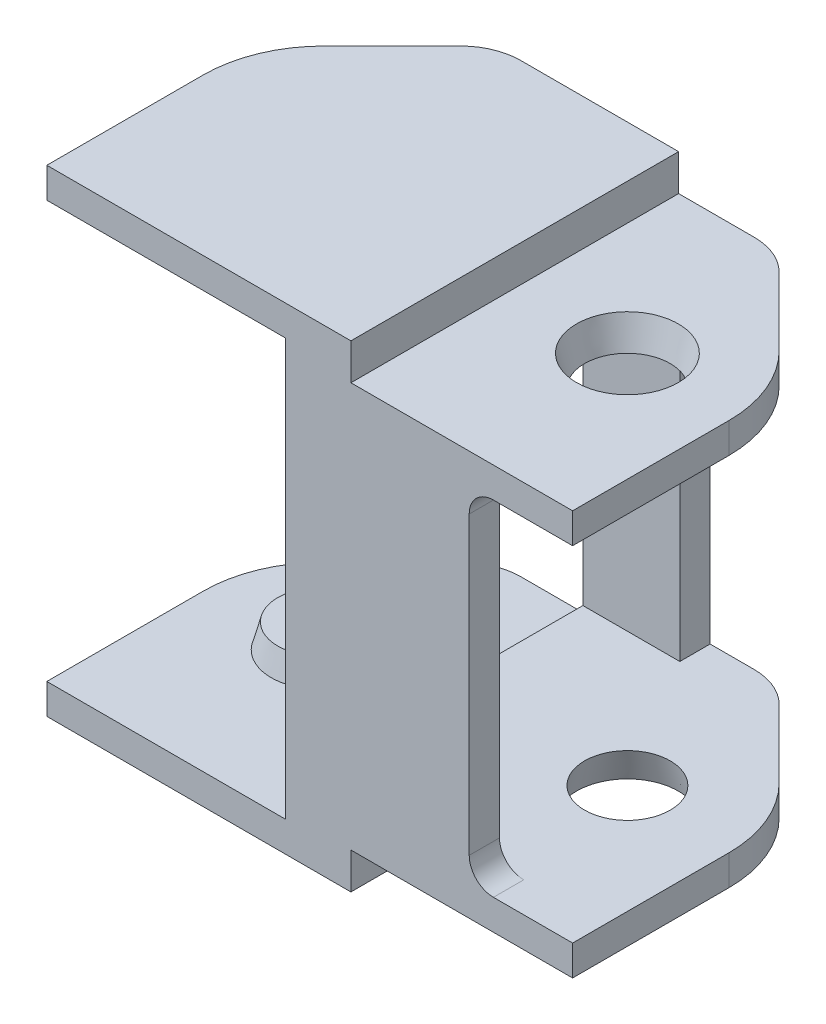
from build123d import *

# Parameters (mm, degrees)
BOSS_EXTRUDE1_DEPTH = 13.525
SKETCH3_W           = 11.025
SKETCH3_H           = 14.2
CUT_EXTRUDE1_DEPTH  = 5
SKETCH4_R           = 2
BOSS_PIVOT_DEPTH    = 1
BOSS_PIVOT_TAPER    = 15
SKETCH6_R           = 2.1
PIVOT_RECESS_DEPTH  = 1.25
PIVOT_RECESS_TAPER  = 15
CHAMFER5_SIZE       = 5
FILLET2_R           = 5
FILLET3_R           = 2.5
SKETCH8_W           = 3.997196271
SKETCH8_H           = 14.2
BOSS_EXTRUDE4_DEPTH = 1.25
FILLET4_R           = 1


with BuildPart() as part:
    # Sketch1 → Boss-Extrude1 (new body)
    with BuildSketch(Plane.XY):
        Polygon((5.35, 3.25), (5.35, 1.25), (-4.5, 1.25), (-4.5, 0), (8.05, 0), (8.05, 1.5), (17.2, 1.5), (17.2, 2.75), (9.35, 2.75), (9.35, 16.95), (17.2, 16.95), (17.2, 18.2), (8.05, 18.2), (8.05, 19.7), (-4.5, 19.7), (-4.5, 18.45), (5.35, 18.45), align=None)
    extrude(amount=BOSS_EXTRUDE1_DEPTH)

    # Sketch3 → Cut-Extrude1 (cut)
    with BuildSketch(Plane(origin=(9.35, 0, 0), x_dir=(0, 0, -1), z_dir=(1, 0, 0))):
        with Locations((-6.7625, 9.85)):
            Rectangle(SKETCH3_W, SKETCH3_H)
    extrude(amount=-CUT_EXTRUDE1_DEPTH, mode=Mode.SUBTRACT)

    # Sketch4 → boss pivot (add)
    with BuildSketch(Plane.XZ.offset(-18.45)):
        with Locations((0, 6.7625)):
            Circle(SKETCH4_R)
    boss_pivot = extrude(amount=BOSS_PIVOT_DEPTH, taper=BOSS_PIVOT_TAPER)

    # Sketch6 → pivot recess (cut)
    with BuildSketch(Plane(origin=(0, 18.2, 0), x_dir=(1, 0, 0), z_dir=(0, 1, 0))):
        with Locations((12.7, -6.7625)):
            Circle(SKETCH6_R)
    pivot_recess = extrude(amount=-PIVOT_RECESS_DEPTH, taper=PIVOT_RECESS_TAPER, mode=Mode.SUBTRACT)

    # Mirror1: boss pivot, pivot recess across plane
    add(boss_pivot.mirror(Plane.ZX.offset(9.85)))
    add(pivot_recess.mirror(Plane.ZX.offset(9.85)), mode=Mode.SUBTRACT)

    # Chamfer5
    chamfer5_edges = [part.edges().sort_by_distance(p)[0] for p in [
        (-4.5, 0.625, 0),
        (-4.5, 19.075, 0),
        (17.2, 17.575, 0),
        (17.2, 2.125, 0),
    ]]
    chamfer(chamfer5_edges, length=CHAMFER5_SIZE)

    # Fillet2
    fillet2_edges = [part.edges().sort_by_distance(p)[0] for p in [
        (17.2, 17.575, 5),
        (17.2, 2.125, 5),
        (-4.5, 0.625, 5),
        (-4.5, 19.075, 5),
    ]]
    fillet(fillet2_edges, radius=FILLET2_R)

    # Fillet3
    fillet3_edges = [part.edges().sort_by_distance(p)[0] for p in [
        (0.5, 19.075, 0),
        (0.5, 0.625, 0),
        (12.2, 2.125, 0),
        (12.2, 17.575, 0),
    ]]
    fillet(fillet3_edges, radius=FILLET3_R)

    # Sketch8 → Boss-Extrude4 (add)
    with BuildSketch(Plane.XY.offset(13.525)):
        with Locations((10.933634912, 9.85)):
            Rectangle(SKETCH8_W, SKETCH8_H)
    extrude(amount=-BOSS_EXTRUDE4_DEPTH)

    # Fillet4
    fillet4_edges = [part.edges().sort_by_distance(p)[0] for p in [
        (12.932233047, 16.95, 12.9),
        (12.932233047, 2.75, 12.9),
    ]]
    fillet(fillet4_edges, radius=FILLET4_R)


solid = part.part
